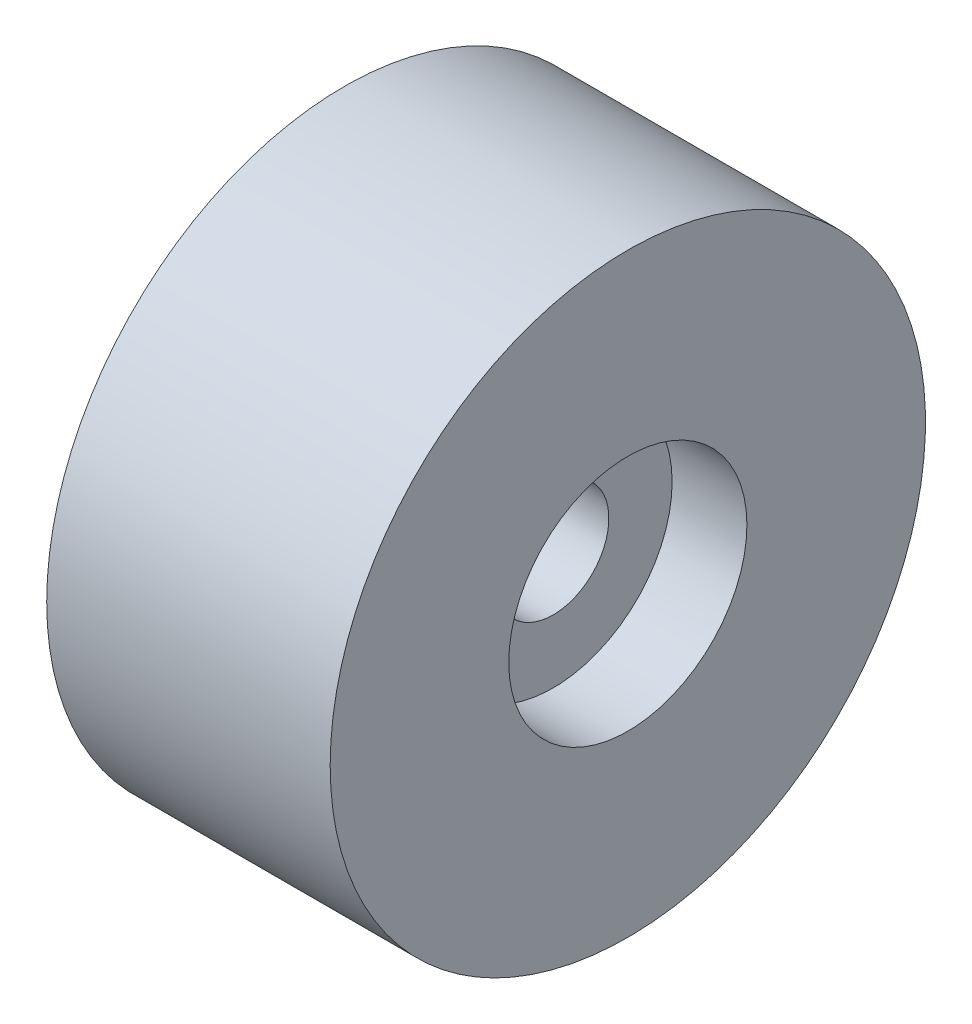
from build123d import *


with BuildPart() as part:
    # Sketch1 → Revolve1 (revolve)
    with BuildSketch(Plane.XY):
        Polygon((0, -25), (0, -133.35), (-63.5, -133.35), (-63.5, -53.35), (-30, -53.35), (-30, -25), align=None)
    revolve1 = revolve(axis=Axis((-62.857142857, 0, 0), (1, 0, 0)))

    # Mirror1: Revolve1 across plane
    add(revolve1.mirror(Plane(origin=(0, 0, 0), x_dir=(0, 0, 1), z_dir=(1, 0, 0))))


solid = part.part
